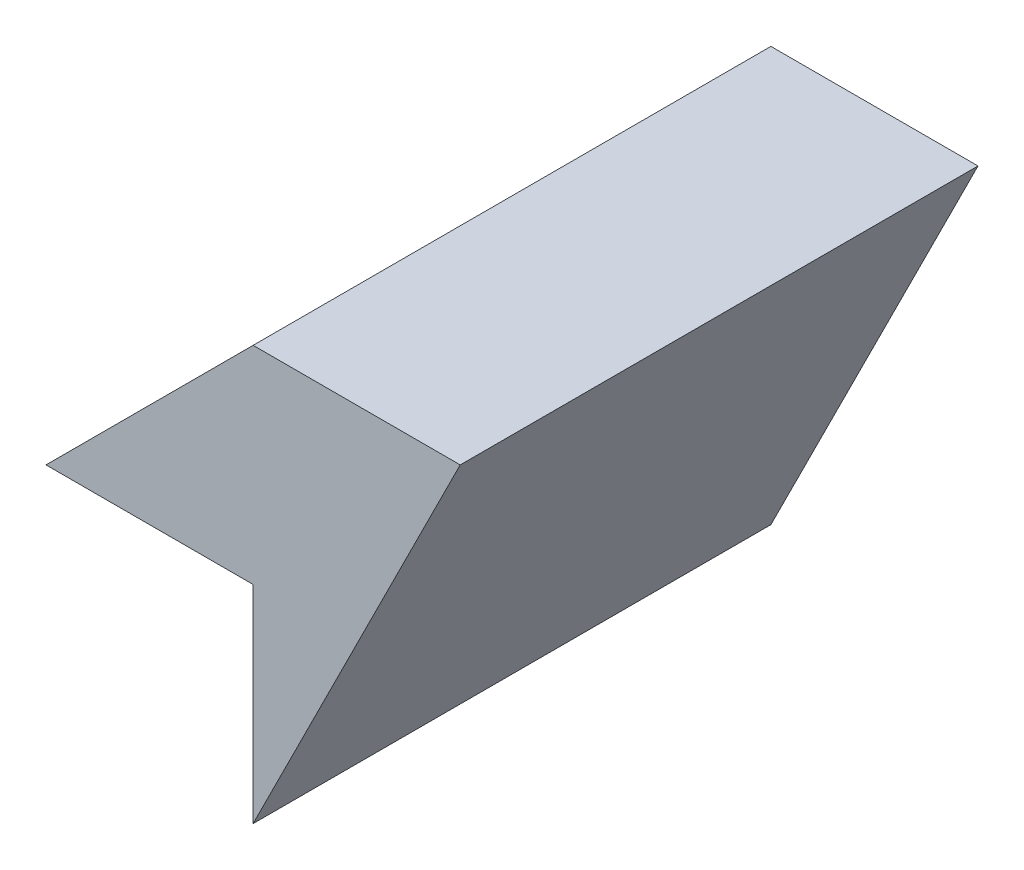
from build123d import *

# Parameters (mm, degrees)
BOSS_EXTRUDE1_DEPTH = 25


with BuildPart() as part:
    # Sketch1 → Boss-Extrude1 (new body)
    with BuildSketch(Plane.XY):
        Polygon((-20, -10), (-10, 0), (0, 0), (-10, -20), (-10, -10), align=None)
    extrude(amount=BOSS_EXTRUDE1_DEPTH)


solid = part.part
